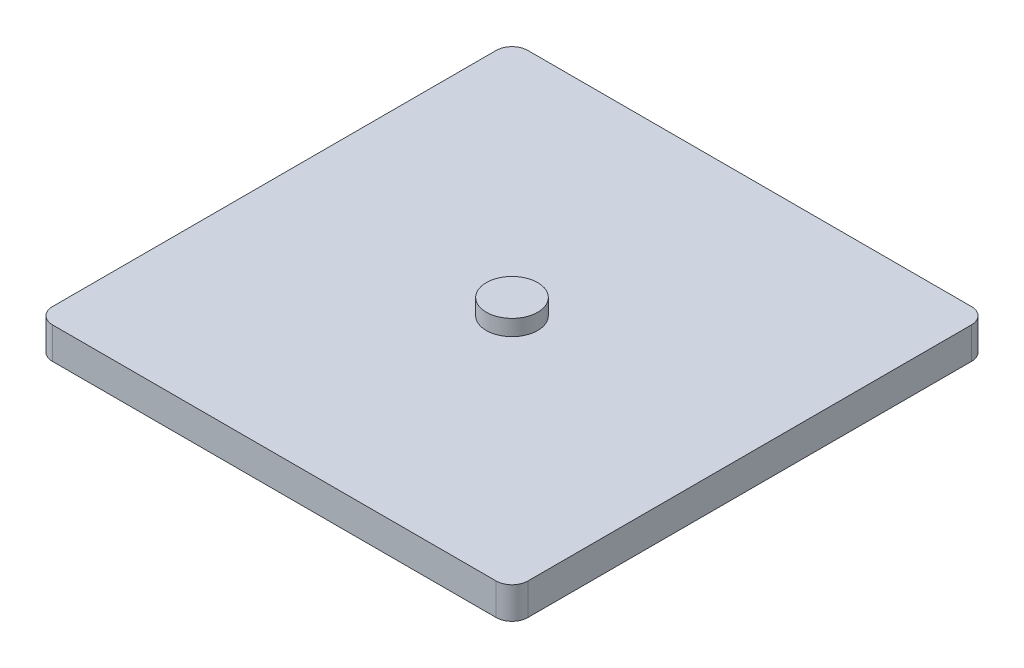
from build123d import *

# Parameters (mm, degrees)
SKETCH1_W           = 300
SKETCH1_H           = 300
BOSS_EXTRUDE1_DEPTH = 20
FILLET1_R           = 10
SKETCH2_R           = 16.222477604
BOSS_EXTRUDE2_DEPTH = 10


with BuildPart() as part:
    # Sketch1 → Boss-Extrude1 (new body)
    with BuildSketch(Plane(origin=(0, 0, 0), x_dir=(1, 0, 0), z_dir=(0, 1, 0))):
        Rectangle(SKETCH1_W, SKETCH1_H)
    extrude(amount=BOSS_EXTRUDE1_DEPTH)

    # Fillet1
    fillet1_edges = [part.edges().sort_by_distance(p)[0] for p in [
        (150, 10, 150),
        (-150, 10, 150),
        (-150, 10, -150),
        (150, 10, -150),
    ]]
    fillet(fillet1_edges, radius=FILLET1_R)

    # Sketch2 → Boss-Extrude2 (add)
    with BuildSketch(Plane(origin=(0, 20, 0), x_dir=(1, 0, 0), z_dir=(0, 1, 0))):
        Circle(SKETCH2_R)
    extrude(amount=BOSS_EXTRUDE2_DEPTH)


solid = part.part
